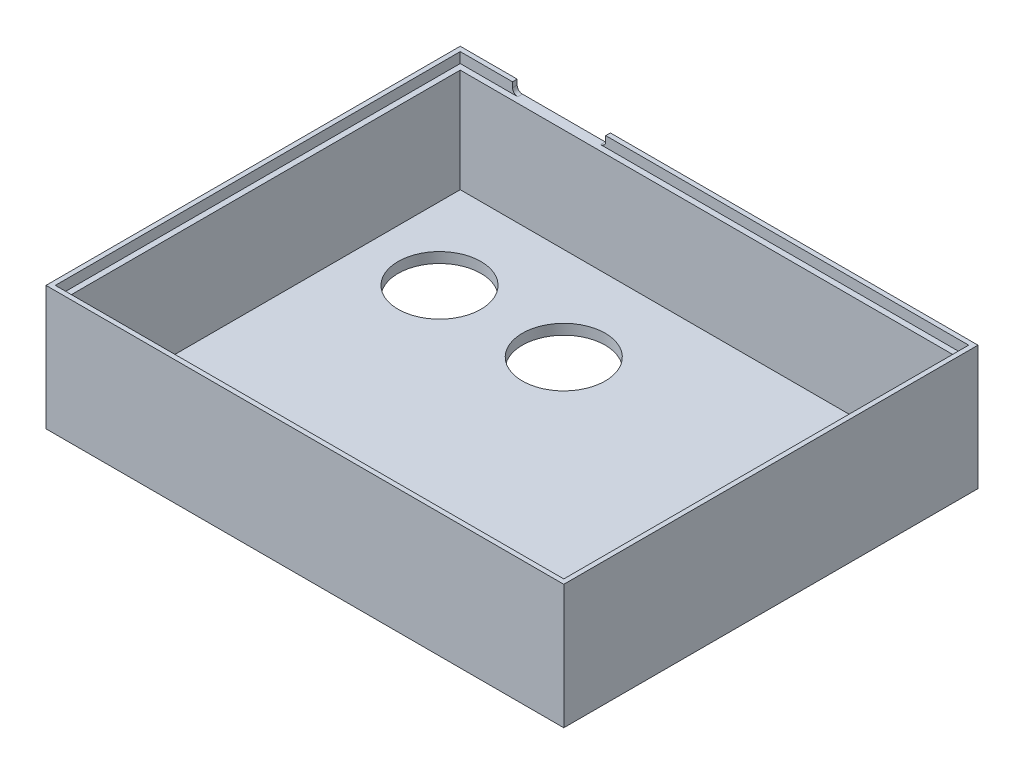
from build123d import *

# Parameters (mm, degrees)
ESQUISSE1_W             = 100
ESQUISSE1_H             = 80
BOSS_EXTRU_1_DEPTH      = 2
ESQUISSE2_W             = 100
ESQUISSE2_H             = 80
ESQUISSE2_W_2           = 96
ESQUISSE2_H_2           = 76
BOSS_EXTRU_2_DEPTH      = 20
ESQUISSE5_W             = 100
ESQUISSE5_H             = 80
ESQUISSE5_W_2           = 98.2
ESQUISSE5_H_2           = 78.2
BOSS_EXTRU_3_DEPTH      = 2
ESQUISSE6_W             = 18
ESQUISSE6_H             = 2
ENL_V_MAT_EXTRU_3_DEPTH = 10
CONG_1_R                = 1
ESQUISSE7_R             = 8
ENL_V_MAT_EXTRU_4_DEPTH = 10


with BuildPart() as part:
    # Esquisse1 → Boss.-Extru.1 (new body)
    with BuildSketch(Plane(origin=(0, 0, 0), x_dir=(1, 0, 0), z_dir=(0, 1, 0))):
        Rectangle(ESQUISSE1_W, ESQUISSE1_H)
    extrude(amount=BOSS_EXTRU_1_DEPTH)

    # Esquisse2 → Boss.-Extru.2 (add)
    with BuildSketch(Plane(origin=(0, 2, 0), x_dir=(1, 0, 0), z_dir=(0, 1, 0))):
        Rectangle(ESQUISSE2_W, ESQUISSE2_H)
        Rectangle(ESQUISSE2_W_2, ESQUISSE2_H_2, mode=Mode.SUBTRACT)
    extrude(amount=BOSS_EXTRU_2_DEPTH)

    # Esquisse5 → Boss.-Extru.3 (add)
    with BuildSketch(Plane(origin=(0, 22, 0), x_dir=(1, 0, 0), z_dir=(0, 1, 0))):
        Rectangle(ESQUISSE5_W, ESQUISSE5_H)
        Rectangle(ESQUISSE5_W_2, ESQUISSE5_H_2, mode=Mode.SUBTRACT)
    extrude(amount=BOSS_EXTRU_3_DEPTH)

    # Esquisse6 → Enlèv. mat.-Extru.3 (cut)
    with BuildSketch(Plane(origin=(0, 0, -40), x_dir=(-1, 0, 0), z_dir=(0, 0, -1))):
        with Locations((30, 23)):
            Rectangle(ESQUISSE6_W, ESQUISSE6_H)
    extrude(amount=-ENL_V_MAT_EXTRU_3_DEPTH, mode=Mode.SUBTRACT)

    # Congé1
    cong_1_edges = [part.edges().sort_by_distance(p)[0] for p in [
        (-39, 22, -39.55),
        (-21, 22, -39.55),
    ]]
    fillet(cong_1_edges, radius=CONG_1_R)

    # Esquisse7 → Enlèv. mat.-Extru.4 (cut)
    with BuildSketch(Plane.XZ):
        with Locations((-34, -20)):
            Circle(ESQUISSE7_R)
        with Locations((-10, -20)):
            Circle(ESQUISSE7_R)
    extrude(amount=-ENL_V_MAT_EXTRU_4_DEPTH, mode=Mode.SUBTRACT)


solid = part.part
